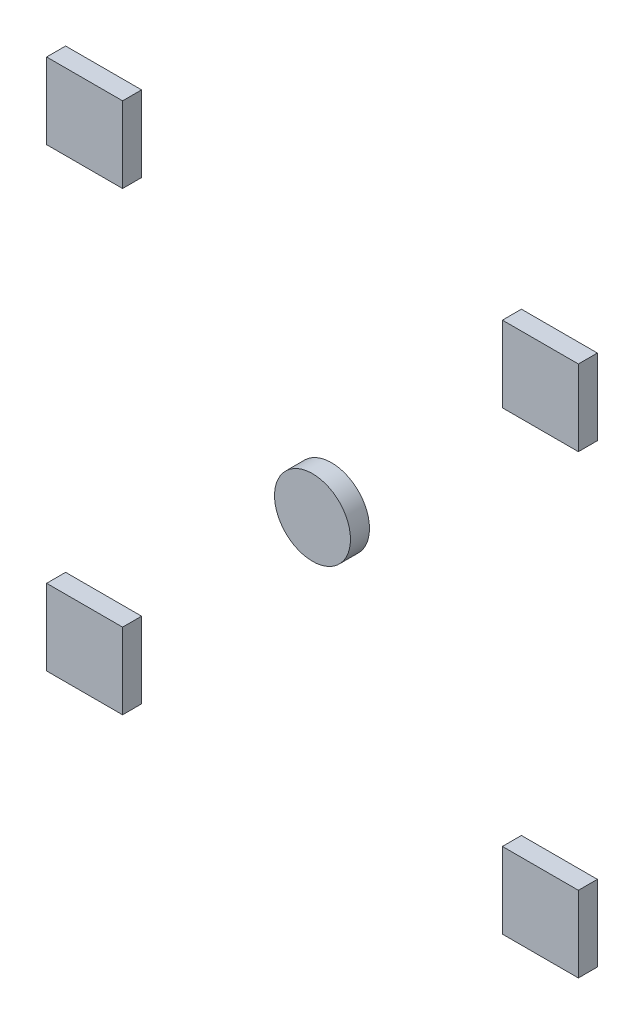
from build123d import *

# Parameters (mm, degrees)
CROQUIS2_R       = 10
EXTRUIR1_DEPTH   = 5
CROQUIS2_W       = 20
CROQUIS2_H       = 20
EXTRUIR1_2_DEPTH = 5
EXTRUIR1_3_DEPTH = 5
EXTRUIR1_4_DEPTH = 5
EXTRUIR1_5_DEPTH = 5


with BuildPart() as part:
    # Croquis2 → Extruir1 (new body)
    with BuildSketch(Plane.XY):
        with Locations((70, 70)):
            Circle(CROQUIS2_R)
    extrude(amount=EXTRUIR1_DEPTH)


with BuildPart() as body_2:
    # Croquis2 → Extruir1 2 (new body)
    with BuildSketch(Plane.XY):
        with Locations((130, 10)):
            Rectangle(CROQUIS2_W, CROQUIS2_H)
    extrude(amount=EXTRUIR1_2_DEPTH)


with BuildPart() as body_3:
    # Croquis2 → Extruir1 3 (new body)
    with BuildSketch(Plane.XY):
        with Locations((10, 10)):
            Rectangle(CROQUIS2_W, CROQUIS2_H)
    extrude(amount=EXTRUIR1_3_DEPTH)


with BuildPart() as body_4:
    # Croquis2 → Extruir1 4 (new body)
    with BuildSketch(Plane.XY):
        with Locations((10, 130)):
            Rectangle(CROQUIS2_W, CROQUIS2_H)
    extrude(amount=EXTRUIR1_4_DEPTH)


with BuildPart() as body_5:
    # Croquis2 → Extruir1 5 (new body)
    with BuildSketch(Plane.XY):
        with Locations((130, 130)):
            Rectangle(CROQUIS2_W, CROQUIS2_H)
    extrude(amount=EXTRUIR1_5_DEPTH)


solid = Compound([part.part, body_2.part, body_3.part, body_4.part, body_5.part])
